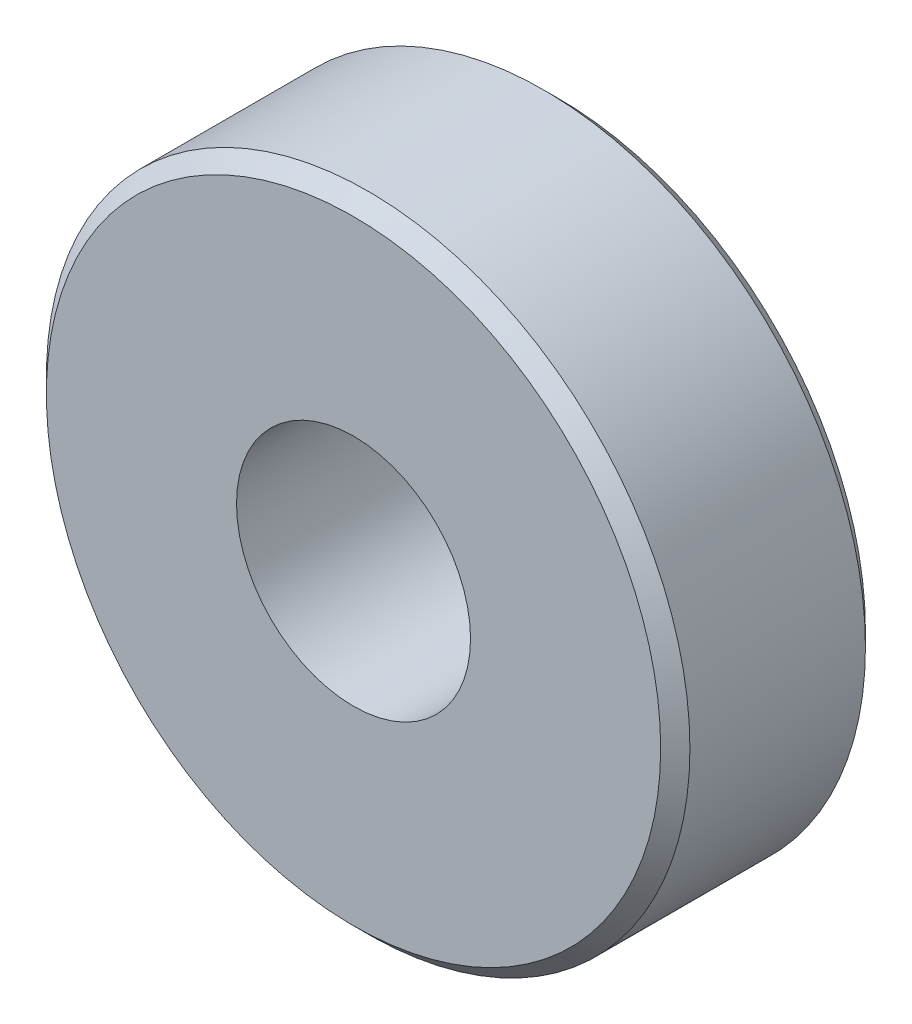
from build123d import *

# Parameters (mm, degrees)
ESBO_O1_R                = 11
ESBO_O1_R_2              = 4
RESSALTO_EXTRUS_O1_DEPTH = 7
CHANFRO1_SIZE            = 0.5


with BuildPart() as part:
    # Esboço1 → Ressalto-extrusão1 (new body)
    with BuildSketch(Plane.XY):
        Circle(ESBO_O1_R)
        Circle(ESBO_O1_R_2, mode=Mode.SUBTRACT)
    extrude(amount=RESSALTO_EXTRUS_O1_DEPTH)

    # Chanfro1
    chanfro1_edges = [part.edges().sort_by_distance(p)[0] for p in [
        (-11, 0, 0),
        (-11, 0, 7),
    ]]
    chamfer(chanfro1_edges, length=CHANFRO1_SIZE)


solid = part.part
